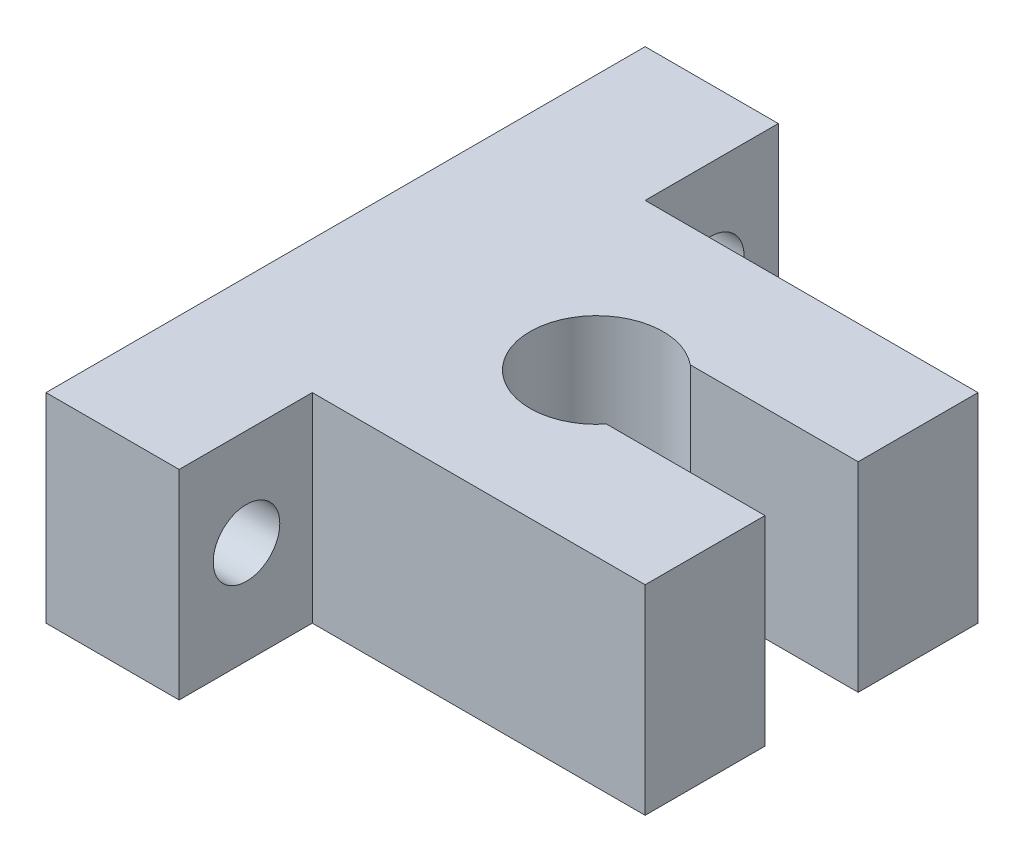
from build123d import *

# Parameters (mm, degrees)
BOSS_EXTRUDE1_DEPTH = 15
SKETCH5_R           = 2.5
CUT_EXTRUDE1_DEPTH  = 10


with BuildPart() as part:
    # Sketch1 → Boss-Extrude1 (new body)
    with BuildSketch(Plane(origin=(0, 0, 0), x_dir=(1, 0, 0), z_dir=(0, 1, 0))):
        with BuildLine():
            Line((0, 22.856339564), (0, -22.143660436))
            Line((0, -22.143660436), (10, -22.143660436))
            Line((10, -22.143660436), (10, -12.143660436))
            Line((10, -12.143660436), (35, -12.143660436))
            Line((35, -12.143660436), (35, -3.143660436))
            Line((35, -3.143660436), (23.095240671, -3.143660436))
            ThreePointArc((23.095240671, -3.143660436), (14.232337293, -0.501428414), (22.389683957, 3.856339564))
            Line((22.389683957, 3.856339564), (35, 3.856339564))
            Line((35, 3.856339564), (35, 12.856339564))
            Line((35, 12.856339564), (10, 12.856339564))
            Line((10, 12.856339564), (10, 22.856339564))
            Line((10, 22.856339564), (0, 22.856339564))
        make_face()
    extrude(amount=BOSS_EXTRUDE1_DEPTH)

    # Sketch5 → Cut-Extrude1 (cut)
    with BuildSketch(Plane(origin=(10, 0, 0), x_dir=(0, 0, -1), z_dir=(1, 0, 0))):
        with Locations((-17.085223361, 7.697334505)):
            Circle(SKETCH5_R)
        with Locations((17.783324683, 7.697334505)):
            Circle(SKETCH5_R)
    extrude(amount=-CUT_EXTRUDE1_DEPTH, mode=Mode.SUBTRACT)


solid = part.part
